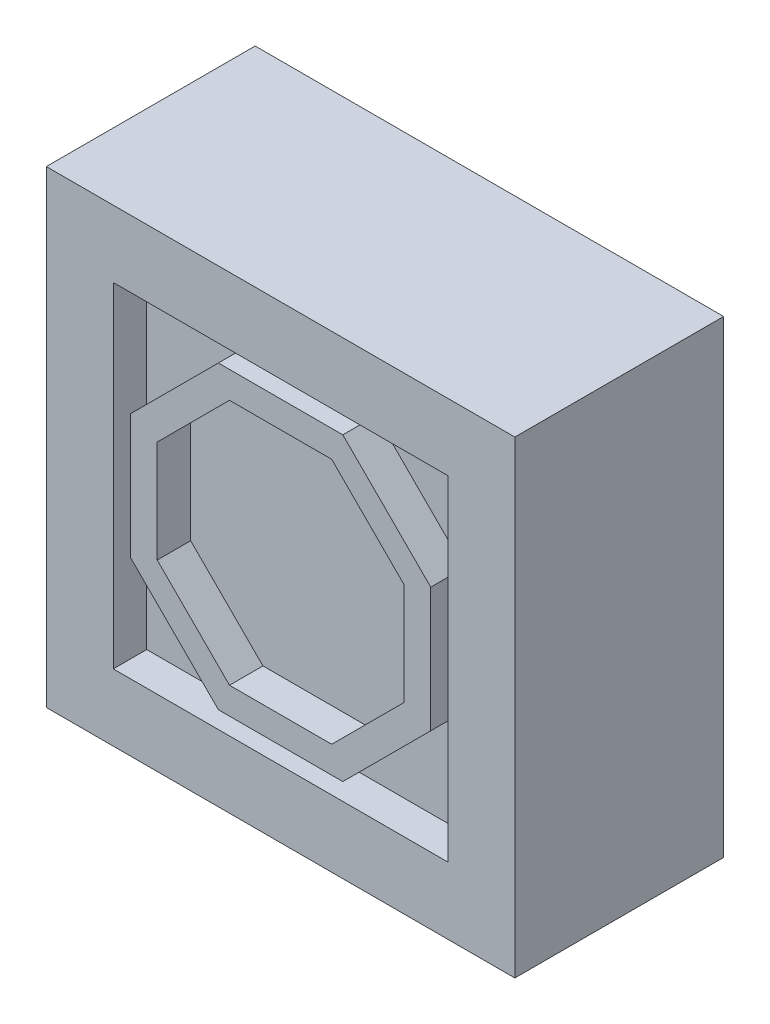
from build123d import *

# Parameters (mm, degrees)
SKETCH1_W           = 3.5
SKETCH1_H           = 3.5
BOSS_EXTRUDE1_DEPTH = 1.56
SKETCH2_W           = 2.5
SKETCH2_H           = 2.5
CUT_EXTRUDE1_DEPTH  = 0.25
BOSS_EXTRUDE2_DEPTH = 0.25


with BuildPart() as part:
    # Sketch1 → Boss-Extrude1 (new body)
    with BuildSketch(Plane.XY):
        Rectangle(SKETCH1_W, SKETCH1_H)
    extrude(amount=BOSS_EXTRUDE1_DEPTH)

    # Sketch2 → Cut-Extrude1 (cut)
    with BuildSketch(Plane.XY.offset(1.56)):
        Rectangle(SKETCH2_W, SKETCH2_H)
    extrude(amount=-CUT_EXTRUDE1_DEPTH, mode=Mode.SUBTRACT)

    # Sketch3 → Boss-Extrude2 (add)
    with BuildSketch(Plane.XY.offset(1.56)):
        Polygon((-0.4646552, 1.121776886), (-1.121776886, 0.4646552), (-1.121776886, -0.4646552), (-0.4646552, -1.121776886), (0.4646552, -1.121776886), (1.121776886, -0.4646552), (1.121776886, 0.4646552), (0.4646552, 1.121776886), align=None)
        Polygon((-0.381812488, 0.921776886), (-0.921776886, 0.381812488), (-0.921776886, -0.381812488), (-0.381812488, -0.921776886), (0.381812488, -0.921776886), (0.921776886, -0.381812488), (0.921776886, 0.381812488), (0.381812488, 0.921776886), align=None, mode=Mode.SUBTRACT)
    extrude(amount=-BOSS_EXTRUDE2_DEPTH)


solid = part.part
